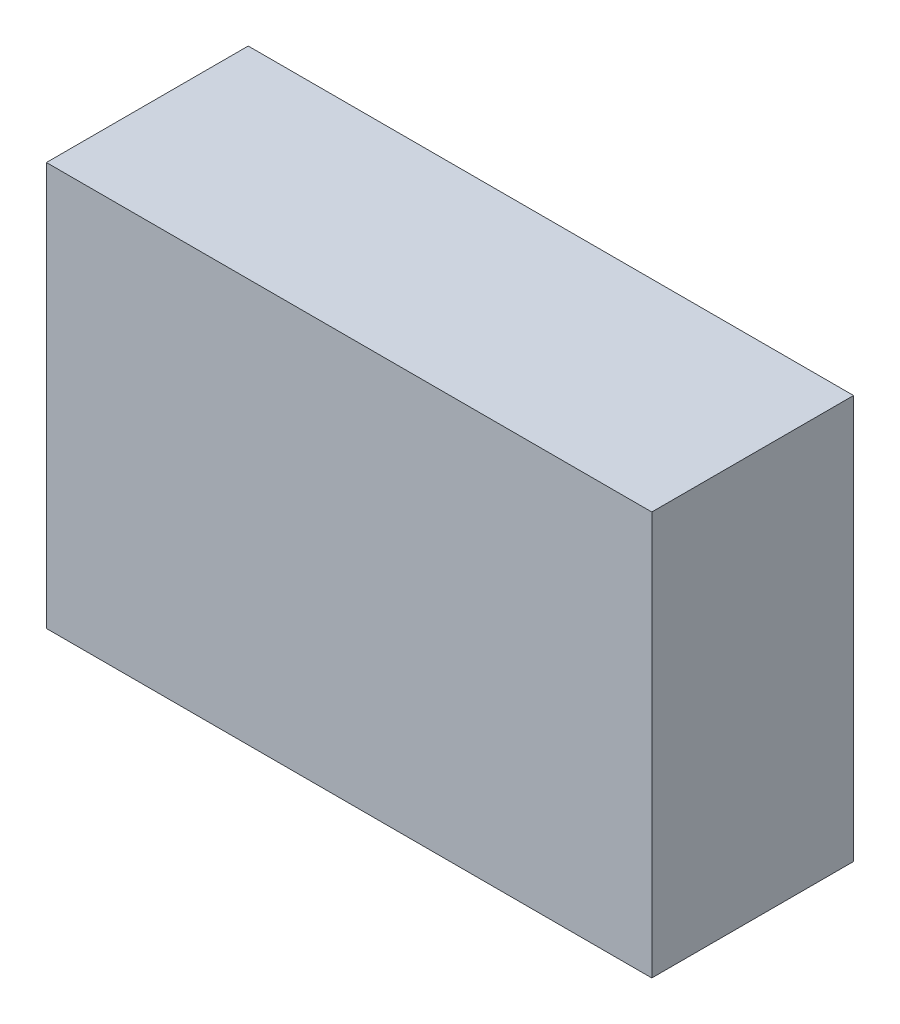
from build123d import *

# Parameters (mm, degrees)
SKETCH1_W           = 152.4
SKETCH1_H           = 101.6
BOSS_EXTRUDE1_DEPTH = 25.4


with BuildPart() as part:
    # Sketch1 → Boss-Extrude1 (new body, symmetric)
    with BuildSketch(Plane.XY):
        with Locations((76.2, 50.8)):
            Rectangle(SKETCH1_W, SKETCH1_H)
    extrude(amount=BOSS_EXTRUDE1_DEPTH, both=True)


solid = part.part
